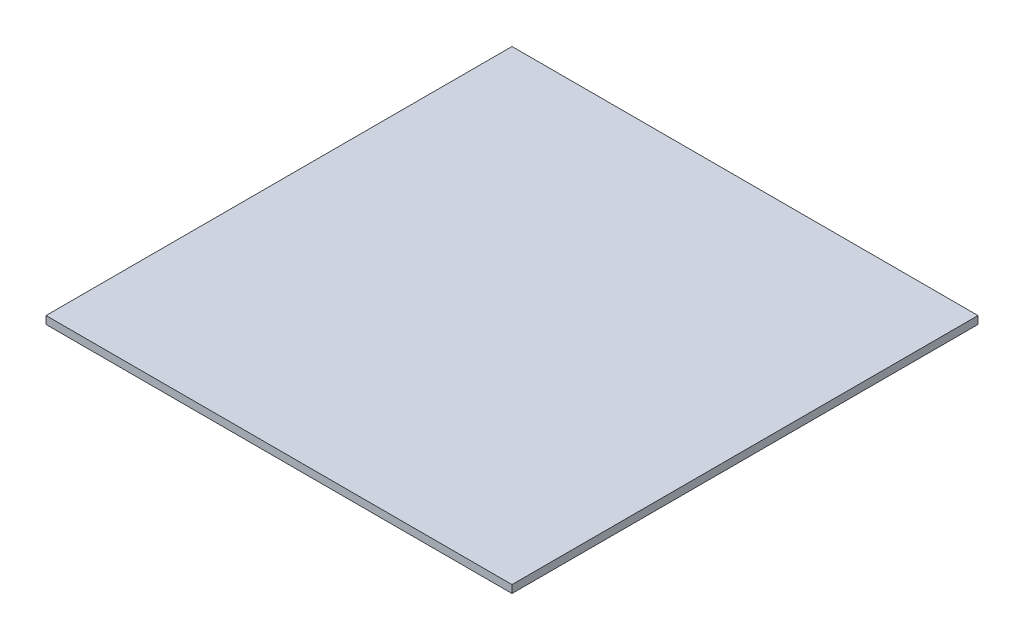
from build123d import *

# Parameters (mm, degrees)
SKETCH1_W           = 300
SKETCH1_H           = 300
BOSS_EXTRUDE1_DEPTH = 5


with BuildPart() as part:
    # Sketch1 → Boss-Extrude1 (new body)
    with BuildSketch(Plane(origin=(0, 0, 0), x_dir=(1, 0, 0), z_dir=(0, 1, 0))):
        Rectangle(SKETCH1_W, SKETCH1_H)
    extrude(amount=BOSS_EXTRUDE1_DEPTH)


solid = part.part
